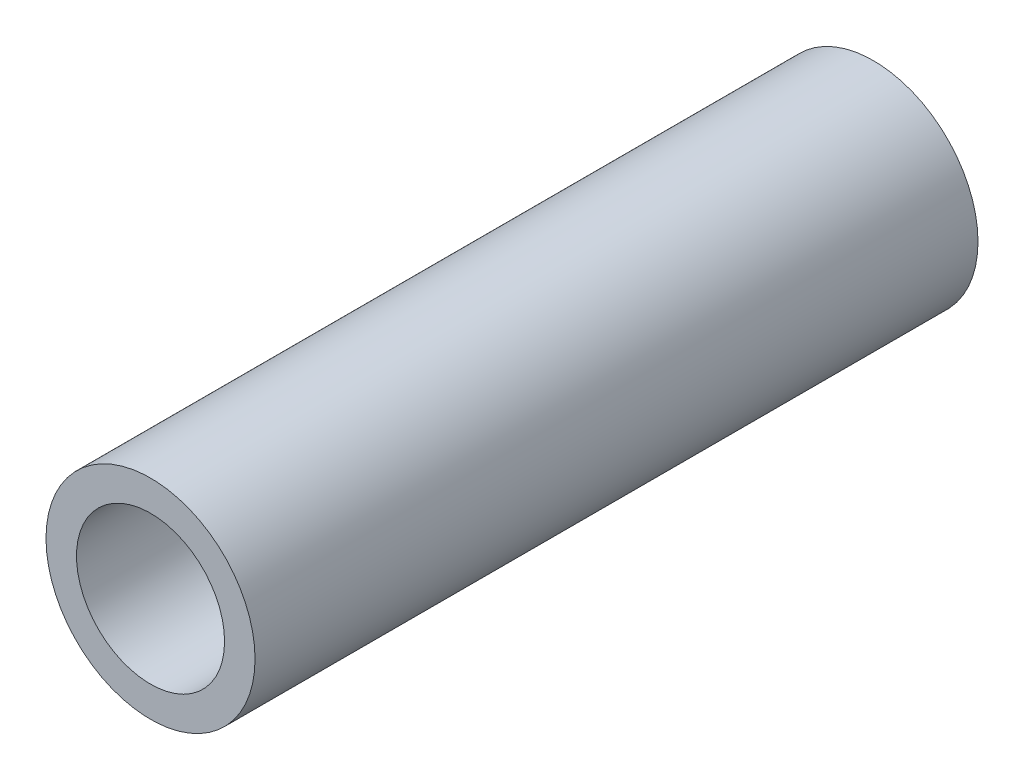
from build123d import *

# Parameters (mm, degrees)
SKETCH1_R           = 12
SKETCH1_R_2         = 8.5
BOSS_EXTRUDE1_DEPTH = 41.5


with BuildPart() as part:
    # Sketch1 → Boss-Extrude1 (new body, symmetric)
    with BuildSketch(Plane.XY):
        Circle(SKETCH1_R)
        Circle(SKETCH1_R_2, mode=Mode.SUBTRACT)
    extrude(amount=BOSS_EXTRUDE1_DEPTH, both=True)


solid = part.part
